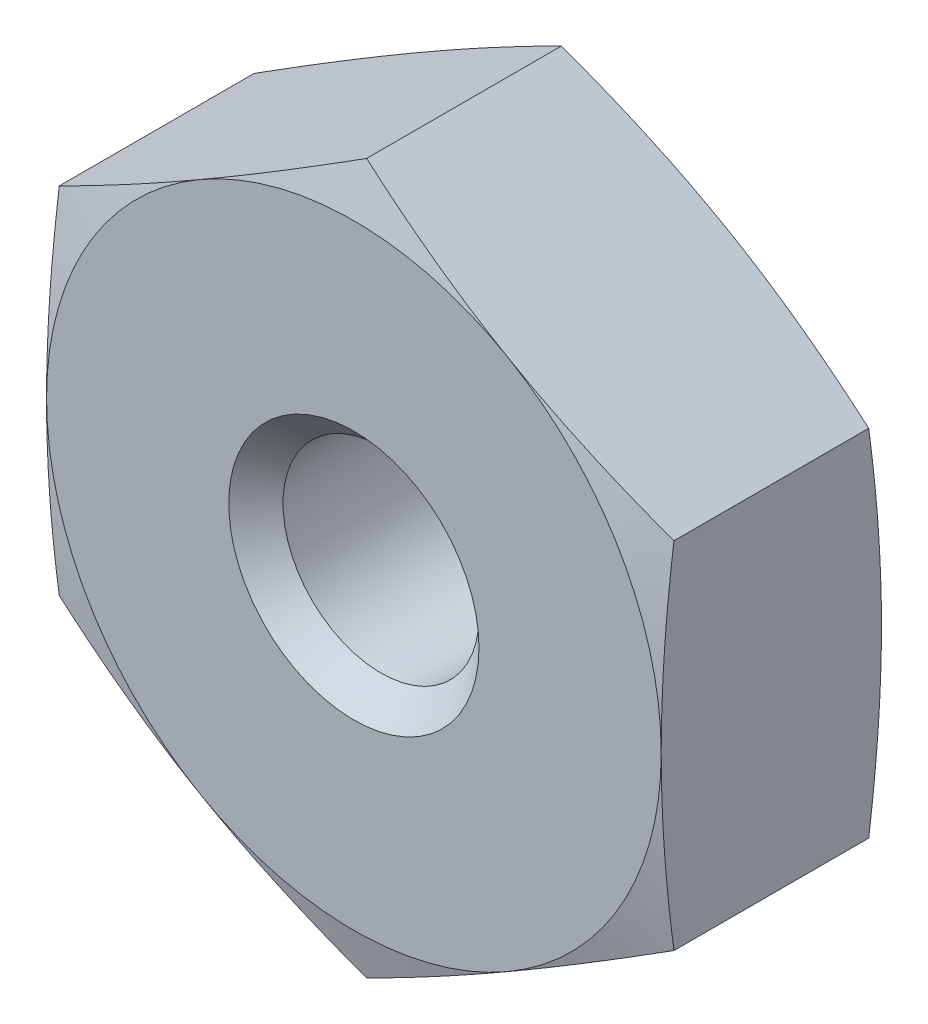
from build123d import *

# Parameters (mm, degrees)
SKETCH2_W          = 15.5956
SKETCH2_H          = 15.5956
CUT_EXTRUDE1_DEPTH = 2.794


with BuildPart() as part:
    # Sketch1 → Revolve1 (revolve)
    with BuildSketch(Plane(origin=(0, 0, 0), x_dir=(0, 0, -1), z_dir=(1, 0, 0))):
        Polygon((0, 0), (0, 3.8989), (0.208941421, 4.67868), (2.585058579, 4.67868), (2.794, 3.8989), (2.794, 0), align=None)
    revolve(axis=Axis((0, 0, -2.794), (0, 0, 1)))

    # Sketch2 → Cut-Extrude1 (cut)
    with BuildSketch(Plane.XY):
        Rectangle(SKETCH2_W, SKETCH2_H)
        Polygon((-3.8989, -2.251030965), (0, -4.502061929), (3.8989, -2.251030965), (3.8989, 2.251030965), (0, 4.502061929), (-3.8989, 2.251030965), align=None, mode=Mode.SUBTRACT)
    extrude(amount=-CUT_EXTRUDE1_DEPTH, mode=Mode.SUBTRACT)

    # Sketch3 → Cut-Revolve1 (revolve, cut)
    with BuildSketch(Plane(origin=(0, 0, 0), x_dir=(0, 0, -1), z_dir=(1, 0, 0))):
        Polygon((0, 0), (0, 1.5875), (0.34417, 1.24333), (2.44983, 1.24333), (2.794, 1.5875), (2.794, 0), align=None)
    revolve(axis=Axis((0, 0, -2.794), (0, 0, 1)), mode=Mode.SUBTRACT)


solid = part.part
